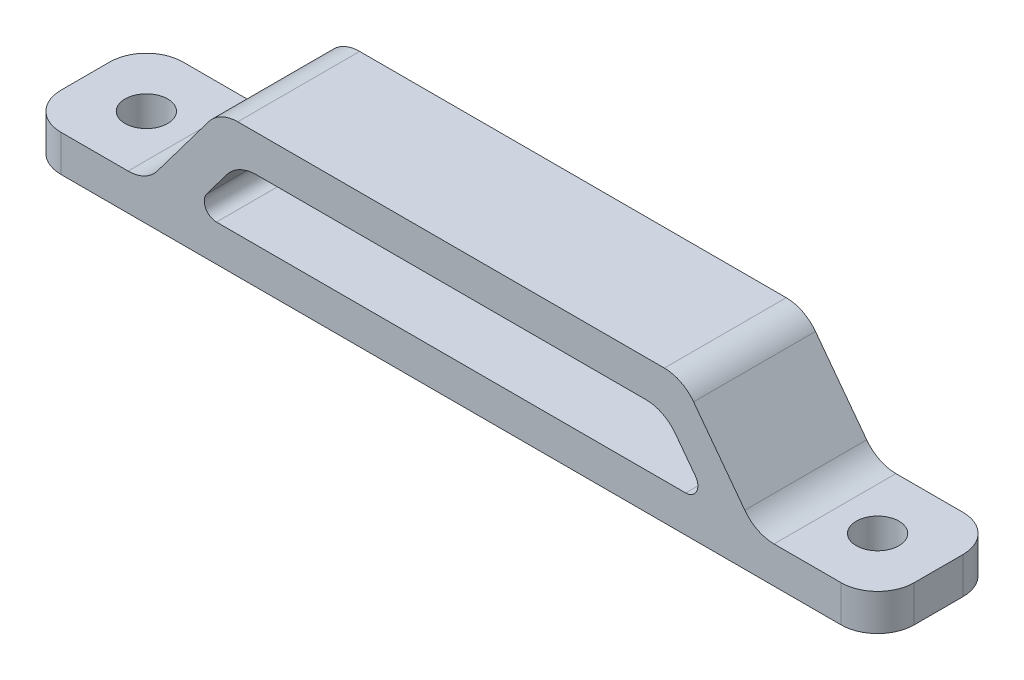
from build123d import *

# Parameters (mm, degrees)
SKETCH1_W           = 70
SKETCH1_H           = 10
SKETCH1_R           = 1.75
BOSS_EXTRUDE1_DEPTH = 3
EXTRUDE_THIN1_DEPTH = 10
CUT_EXTRUDE1_REACH  = 12
FILLET1_R           = 3
FILLET2_R           = 1


with BuildPart() as part:
    # Sketch1 → Boss-Extrude1 (new body)
    with BuildSketch(Plane(origin=(0, 0, 0), x_dir=(1, 0, 0), z_dir=(0, 1, 0))):
        with Locations((35, 5)):
            Rectangle(SKETCH1_W, SKETCH1_H)
        with Locations((5, 5)):
            Circle(SKETCH1_R, mode=Mode.SUBTRACT)
        with Locations((65, 5)):
            Circle(SKETCH1_R, mode=Mode.SUBTRACT)
    extrude(amount=BOSS_EXTRUDE1_DEPTH)

    # Sketch2 → Extrude-Thin1 (add)
    with BuildSketch(Plane.XY):
        Polygon((10, 3), (16, 11), (54, 11), (60, 3), align=None)
        Polygon((16, 6), (17.5, 8), (52.5, 8), (54, 6), align=None, mode=Mode.SUBTRACT)
    extrude(amount=-EXTRUDE_THIN1_DEPTH)

    # Sketch3 → Cut-Extrude1 (cut, up to next)
    with BuildSketch(Plane.XY, mode=Mode.PRIVATE) as cut_extrude1_sk1:
        Polygon((16, 6), (13.75, 3), (56.25, 3), (54, 6), align=None)
    cut_extrude1_tool1 = extrude(cut_extrude1_sk1.sketch, amount=-CUT_EXTRUDE1_REACH, mode=Mode.PRIVATE) & part.part
    add(cut_extrude1_tool1.solids().sort_by_distance((35, 4.47205, 0))[0], mode=Mode.SUBTRACT)

    # Fillet1
    fillet1_edges = [part.edges().sort_by_distance(p)[0] for p in [
        (54, 11, -5),
        (16, 11, -5),
        (10, 3, -5),
        (60, 3, -5),
        (52.5, 8, -5),
        (17.5, 8, -5),
        (0, 1.5, -10),
        (70, 1.5, -10),
        (70, 1.5, 0),
        (0, 1.5, 0),
    ]]
    fillet(fillet1_edges, radius=FILLET1_R)

    # Fillet2
    fillet2_edges = [part.edges().sort_by_distance(p)[0] for p in [
        (56.25, 3, -5),
        (13.75, 3, -5),
    ]]
    fillet(fillet2_edges, radius=FILLET2_R)


solid = part.part
